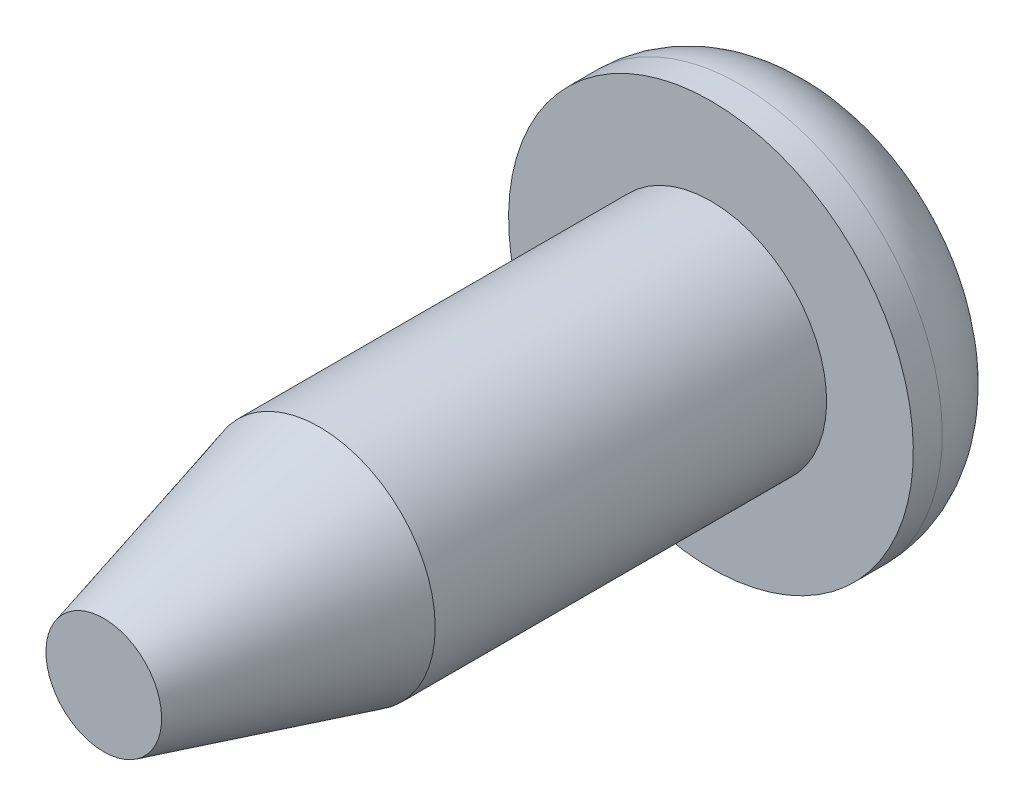
from build123d import *

# Parameters (mm, degrees)
CUT_EXTRUDE1_DEPTH = 0.762
CHAMFER1_SIZE      = 0.508
CHAMFER1_SIZE2     = 1.89588181


with BuildPart() as part:
    # Sketch1 → Revolve1 (revolve)
    with BuildSketch(Plane(origin=(0, 0, 0), x_dir=(0, 0, -1), z_dir=(1, 0, 0))):
        with BuildLine():
            Line((0, 0), (-6.35, 0))
            Line((-6.35, 0), (-6.35, 1.016))
            Line((-6.35, 1.016), (-1.016, 1.016))
            Line((-1.016, 1.016), (-1.016, 1.778))
            Line((-1.016, 1.778), (-0.762, 1.778))
            ThreePointArc((-0.762, 1.778), (-0.223184633, 1.554815367), (0, 1.016))
            Line((0, 1.016), (0, 0))
        make_face()
    revolve(axis=Axis((0, 0, 0), (0, 0, 1)))

    # Sketch2 → Cut-Extrude1 (cut)
    with BuildSketch(Plane(origin=(0, 0, 0), x_dir=(-1, 0, 0), z_dir=(0, 0, -1))):
        Polygon((0.195962003, -1.459943378), (-0.195962003, -1.459943378), (-0.195962003, -0.348829462), (-0.348829462, -0.195962003), (-1.459943378, -0.195962003), (-1.459943378, 0.195962003), (-0.348829462, 0.195962003), (-0.195962003, 0.348829462), (-0.195962003, 1.459943378), (0.195962003, 1.459943378), (0.195962003, 0.348829462), (0.348829462, 0.195962003), (1.459943378, 0.195962003), (1.459943378, -0.195962003), (0.348829462, -0.195962003), (0.195962003, -0.348829462), align=None)
    extrude(amount=-CUT_EXTRUDE1_DEPTH, mode=Mode.SUBTRACT)

    # Chamfer1
    chamfer1_edges = [part.edges().sort_by_distance(p)[0] for p in [
        (0, -1.016, 6.35),
    ]]
    chamfer1_side = [part.faces().sort_by_distance(p)[0] for p in [
        (0, 0, 6.35),
    ]]
    chamfer(chamfer1_edges, length=CHAMFER1_SIZE, length2=CHAMFER1_SIZE2, reference=chamfer1_side[0])


solid = part.part
